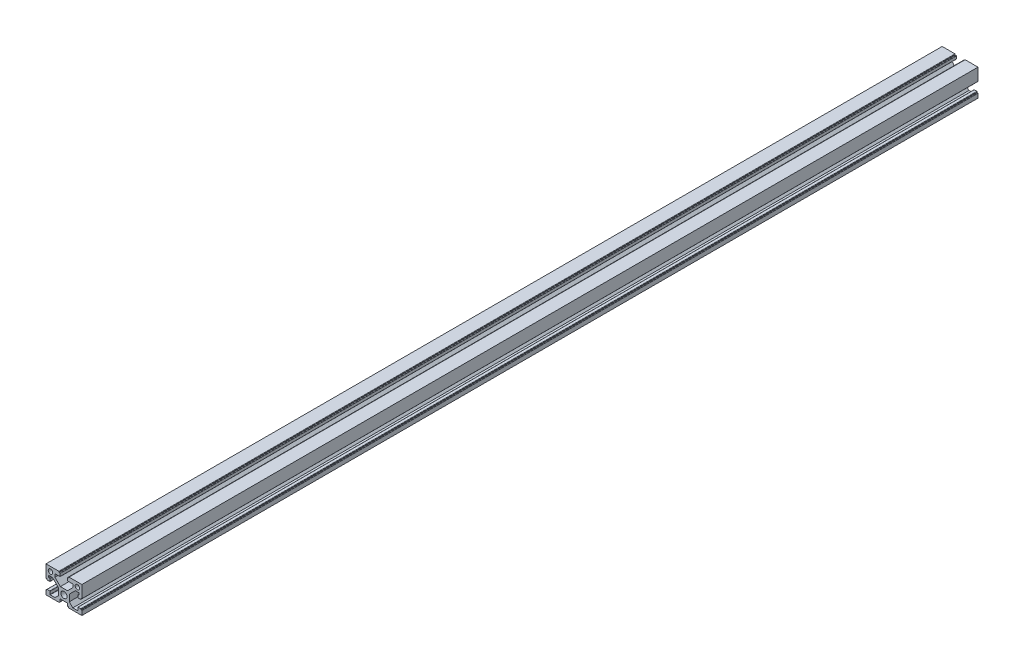
from build123d import *

# Parameters (mm, degrees)
SKETCH_1_R      = 3.4
SKETCH_1_R_2    = 2.5
EXTRUDE_1_DEPTH = 1000


with BuildPart() as part:
    # Эскиз1 → Бобышка-Вытянуть1 (new body)
    with BuildSketch(Plane.XY):
        with BuildLine():
            Line((-10, 20), (-20, 20))
            Line((-20, 20), (-20, 6.3))
            ThreePointArc((-20, 6.3), (-19.912132034, 6.087867966), (-19.7, 6))
            Line((-19.7, 6), (-19, 6))
            Line((-19, 6), (-19, 5.3))
            ThreePointArc((-19, 5.3), (-18.912132034, 5.087867966), (-18.7, 5))
            Line((-18.7, 5), (-15.8, 5))
            ThreePointArc((-15.8, 5), (-15.587867966, 5.087867966), (-15.5, 5.3))
            Line((-15.5, 5.3), (-15.5, 8))
            Line((-15.5, 8), (-16.7, 8))
            ThreePointArc((-16.7, 8), (-16.912132034, 8.087867966), (-17, 8.3))
            Line((-17, 8.3), (-17, 10.1))
            ThreePointArc((-17, 10.1), (-16.912132034, 10.312132034), (-16.7, 10.4))
            Line((-16.7, 10.4), (-12.7, 10.4))
            Line((-12.7, 10.4), (-6, 3.7))
            Line((-6, 3.7), (-6, -3.7))
            Line((-6, -3.7), (-9.9, -7.6))
            Line((-9.9, -7.6), (-15.2, -7.6))
            ThreePointArc((-15.2, -7.6), (-15.412132034, -7.512132034), (-15.5, -7.3))
            Line((-15.5, -7.3), (-15.5, -4.3))
            ThreePointArc((-15.5, -4.3), (-15.587867966, -4.087867966), (-15.8, -4))
            Line((-15.8, -4), (-18.7, -4))
            ThreePointArc((-18.7, -4), (-18.912132034, -4.087867966), (-19, -4.3))
            Line((-19, -4.3), (-19, -5))
            Line((-19, -5), (-19.7, -5))
            ThreePointArc((-19.7, -5), (-19.912132034, -5.087867966), (-20, -5.3))
            Line((-20, -5.3), (-20, -10))
            Line((-20, -10), (-5.4, -10))
            ThreePointArc((-5.4, -10), (-5.187867966, -9.912132034), (-5.1, -9.7))
            Line((-5.1, -9.7), (-5.1, -9))
            Line((-5.1, -9), (-4.4, -9))
            ThreePointArc((-4.4, -9), (-4.187867966, -8.912132034), (-4.1, -8.7))
            Line((-4.1, -8.7), (-4.1, -6))
            Line((-4.1, -6), (4.1, -6))
            Line((4.1, -6), (4.1, -8.7))
            ThreePointArc((4.1, -8.7), (4.187867966, -8.912132034), (4.4, -9))
            Line((4.4, -9), (5.1, -9))
            Line((5.1, -9), (5.1, -9.7))
            ThreePointArc((5.1, -9.7), (5.187867966, -9.912132034), (5.4, -10))
            Line((5.4, -10), (20, -10))
            Line((20, -10), (20, -5.3))
            ThreePointArc((20, -5.3), (19.912132034, -5.087867966), (19.7, -5))
            Line((19.7, -5), (19, -5))
            Line((19, -5), (19, -4.3))
            ThreePointArc((19, -4.3), (18.912132034, -4.087867966), (18.7, -4))
            Line((18.7, -4), (15.8, -4))
            ThreePointArc((15.8, -4), (15.587867966, -4.087867966), (15.5, -4.3))
            Line((15.5, -4.3), (15.5, -7.3))
            ThreePointArc((15.5, -7.3), (15.412132034, -7.512132034), (15.2, -7.6))
            Line((15.2, -7.6), (9.9, -7.6))
            Line((9.9, -7.6), (6, -3.7))
            Line((6, -3.7), (6, 3.7))
            Line((6, 3.7), (12.7, 10.4))
            Line((12.7, 10.4), (16.7, 10.4))
            ThreePointArc((16.7, 10.4), (16.912132034, 10.312132034), (17, 10.1))
            Line((17, 10.1), (17, 8.3))
            ThreePointArc((17, 8.3), (16.912132034, 8.087867966), (16.7, 8))
            Line((16.7, 8), (15.5, 8))
            Line((15.5, 8), (15.5, 5.3))
            ThreePointArc((15.5, 5.3), (15.587867966, 5.087867966), (15.8, 5))
            Line((15.8, 5), (18.7, 5))
            ThreePointArc((18.7, 5), (18.912132034, 5.087867966), (19, 5.3))
            Line((19, 5.3), (19, 6))
            Line((19, 6), (19.7, 6))
            ThreePointArc((19.7, 6), (19.912132034, 6.087867966), (20, 6.3))
            Line((20, 6.3), (20, 20))
            Line((20, 20), (10, 20))
            Line((10, 20), (5.7, 20))
            ThreePointArc((5.7, 20), (5.487867966, 19.912132034), (5.4, 19.7))
            Line((5.4, 19.7), (5.4, 19))
            Line((5.4, 19), (4.4, 19))
            ThreePointArc((4.4, 19), (4.187867966, 18.912132034), (4.1, 18.7))
            Line((4.1, 18.7), (4.1, 15.8))
            ThreePointArc((4.1, 15.8), (4.187867966, 15.587867966), (4.4, 15.5))
            Line((4.4, 15.5), (9.7, 15.5))
            ThreePointArc((9.7, 15.5), (9.912132034, 15.412132034), (10, 15.2))
            Line((10, 15.2), (10, 12))
            Line((10, 12), (4, 6))
            Line((4, 6), (-4, 6))
            Line((-4, 6), (-10, 12))
            Line((-10, 12), (-10, 15.2))
            ThreePointArc((-10, 15.2), (-9.912132034, 15.412132034), (-9.7, 15.5))
            Line((-9.7, 15.5), (-4.4, 15.5))
            ThreePointArc((-4.4, 15.5), (-4.187867966, 15.587867966), (-4.1, 15.8))
            Line((-4.1, 15.8), (-4.1, 18.7))
            ThreePointArc((-4.1, 18.7), (-4.187867966, 18.912132034), (-4.4, 19))
            Line((-4.4, 19), (-5.4, 19))
            Line((-5.4, 19), (-5.4, 19.7))
            ThreePointArc((-5.4, 19.7), (-5.487867966, 19.912132034), (-5.7, 20))
            Line((-5.7, 20), (-10, 20))
        make_face()
        Circle(SKETCH_1_R, mode=Mode.SUBTRACT)
        with Locations((15, 15)):
            Circle(SKETCH_1_R_2, mode=Mode.SUBTRACT)
        with Locations((-15, 15)):
            Circle(SKETCH_1_R_2, mode=Mode.SUBTRACT)
    extrude(amount=EXTRUDE_1_DEPTH)


solid = part.part
